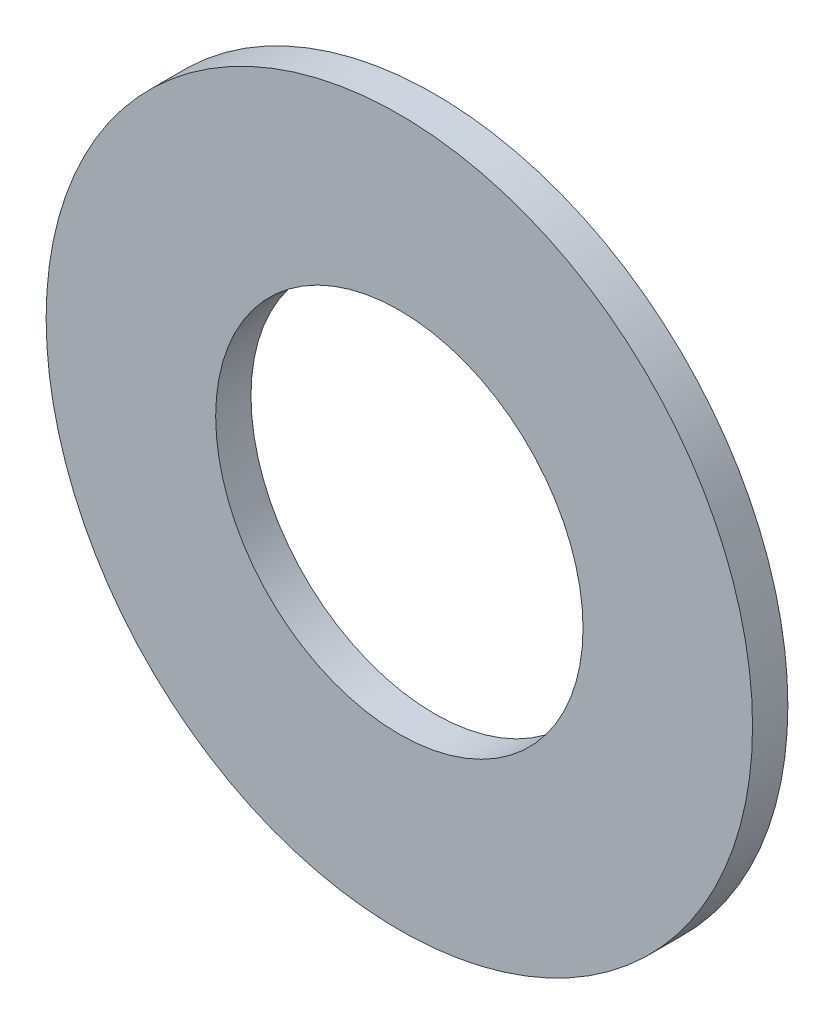
from build123d import *

# Parameters (mm, degrees)
SKETCH_1_R      = 5
SKETCH_1_R_2    = 2.6
EXTRUDE_1_DEPTH = 0.5


with BuildPart() as part:
    # 草图1 → 凸台-拉伸1 (new body)
    with BuildSketch(Plane.XY):
        Circle(SKETCH_1_R)
        Circle(SKETCH_1_R_2, mode=Mode.SUBTRACT)
    extrude(amount=EXTRUDE_1_DEPTH)


solid = part.part
